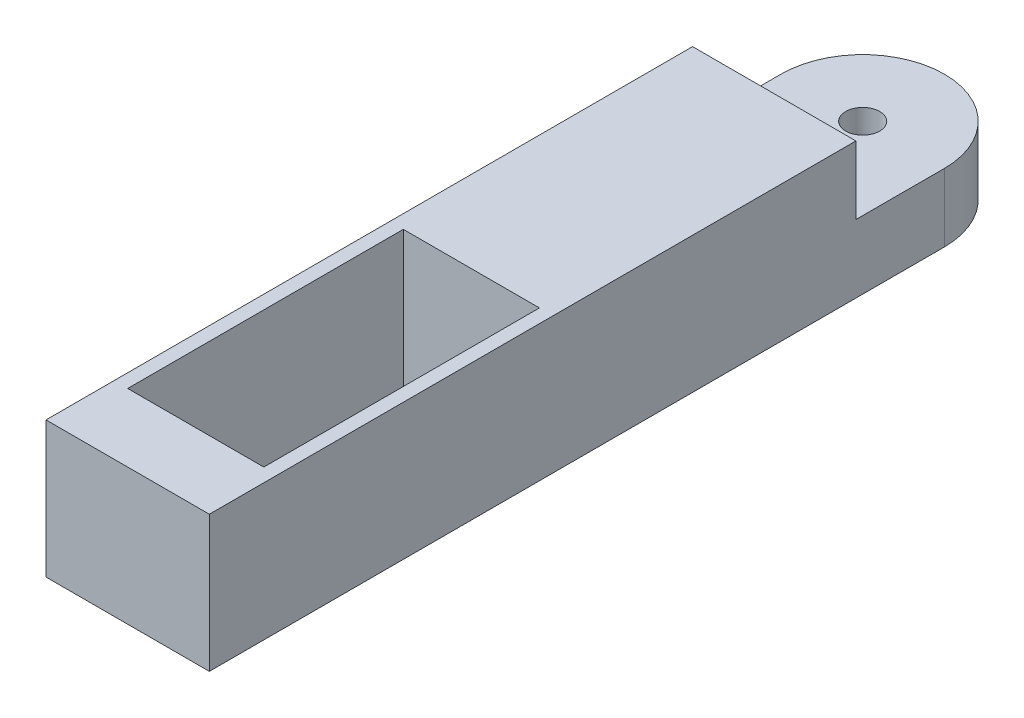
from build123d import *

# Parameters (mm, degrees)
SKETCH3_R                = 2.5
BOSS_EXTRUDE2_DEPTH      = 10
BOSS_EXTRUDE3_DEPTH      = 10
BOSS_EXTRUDE3_DEPTH_BACK = 10
SKETCH4_W                = 24
SKETCH4_H                = 95
SKETCH4_W_2              = 20
SKETCH4_H_2              = 40.5


with BuildPart() as part:
    # Sketch3 → Boss-Extrude2 (new body)
    with BuildSketch(Plane(origin=(0, 0, 0), x_dir=(1, 0, 0), z_dir=(0, 1, 0))):
        with BuildLine():
            ThreePointArc((4, 20), (-8, 32), (-20, 20))
            Line((-20, 20), (-20, 7))
            Line((-20, 7), (4, 7))
            Line((4, 7), (4, 20))
        make_face()
        with Locations((-8, 20)):
            Circle(SKETCH3_R, mode=Mode.SUBTRACT)
    extrude(amount=BOSS_EXTRUDE2_DEPTH)

    # Sketch4 → Boss-Extrude3 (add, two sides: drawn at the far end of the back side and taken through both)
    with BuildSketch(Plane(origin=(0, 10, 0), x_dir=(1, 0, 0), z_dir=(0, 1, 0)).offset(-BOSS_EXTRUDE3_DEPTH_BACK)):
        with Locations((-8, -40.5)):
            Rectangle(SKETCH4_W, SKETCH4_H)
        with Locations((-8, -57.75)):
            Rectangle(SKETCH4_W_2, SKETCH4_H_2, mode=Mode.SUBTRACT)
    extrude(amount=BOSS_EXTRUDE3_DEPTH + BOSS_EXTRUDE3_DEPTH_BACK)


solid = part.part
